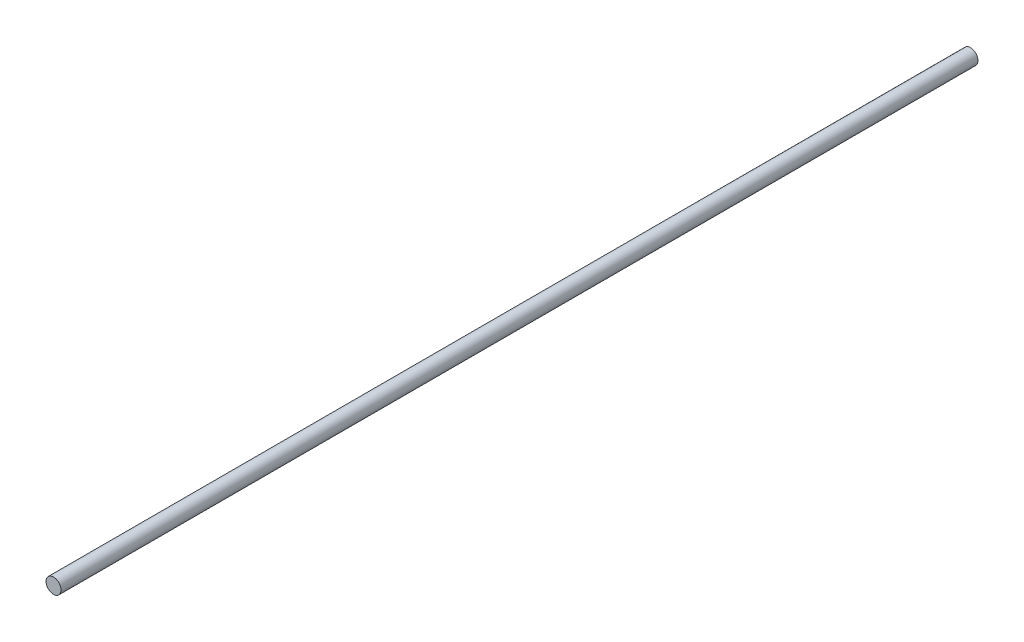
from build123d import *

# Parameters (mm, degrees)
ESQUISSE1_R        = 4
BOSS_EXTRU_1_DEPTH = 488


with BuildPart() as part:
    # Esquisse1 → Boss.-Extru.1 (new body)
    with BuildSketch(Plane.XY):
        Circle(ESQUISSE1_R)
    extrude(amount=BOSS_EXTRU_1_DEPTH)


solid = part.part
